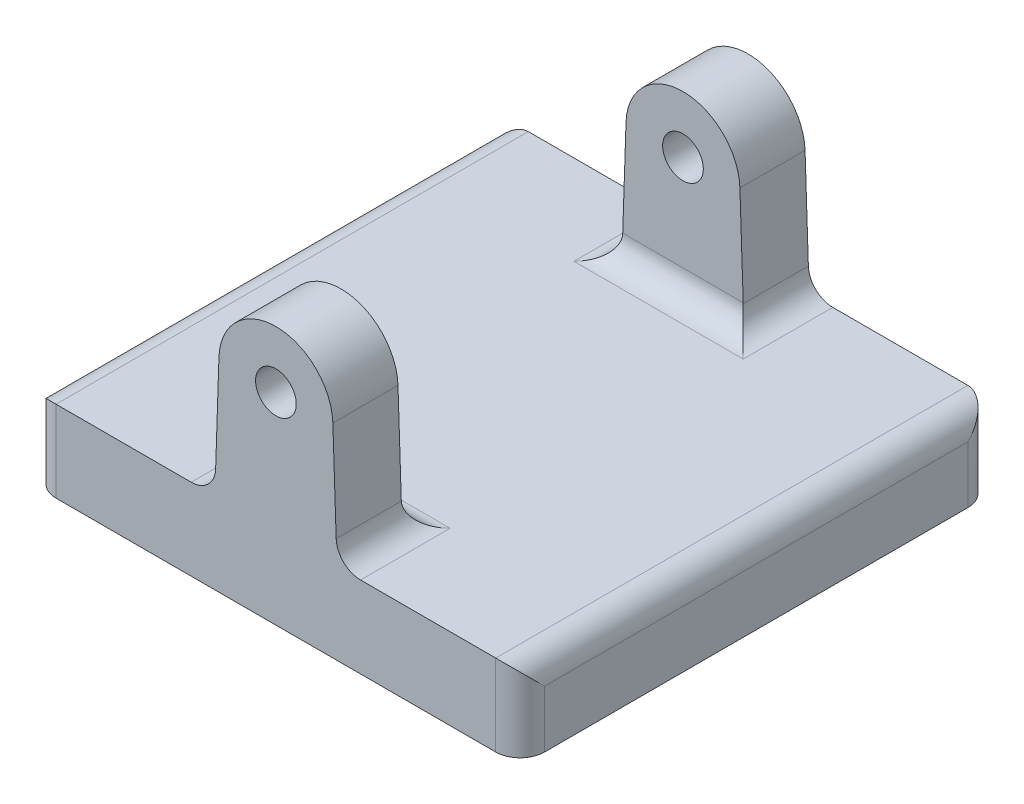
from build123d import *

# Parameters (mm, degrees)
SKETCH2_W           = 60
SKETCH2_H           = 58
BOSS_EXTRUDE1_DEPTH = 10
SKETCH3_R           = 2.5
BOSS_EXTRUDE2_DEPTH = 8
FILLET1_R           = 3


with BuildPart() as part:
    # Sketch2 → Boss-Extrude1 (new body)
    with BuildSketch(Plane(origin=(0, 0, 0), x_dir=(1, 0, 0), z_dir=(0, 1, 0))):
        Rectangle(SKETCH2_W, SKETCH2_H)
    extrude(amount=BOSS_EXTRUDE1_DEPTH)

    # Sketch3 → Boss-Extrude2 (add)
    with BuildSketch(Plane.XY.offset(29)):
        with BuildLine():
            Line((-7.5, 10), (-6.996052809, 25))
            ThreePointArc((-6.996052809, 25), (0, 31.764957256), (6.996052809, 25))
            Line((6.996052809, 25), (7.5, 10))
            Line((7.5, 10), (-7.5, 10))
        make_face()
        with Locations((0, 24.764957256)):
            Circle(SKETCH3_R, mode=Mode.SUBTRACT)
    boss_extrude2 = extrude(amount=-BOSS_EXTRUDE2_DEPTH)

    # Mirror1: Boss-Extrude2 across plane
    add(boss_extrude2.mirror(Plane.XY))

    # Fillet1
    fillet1_edges = [part.edges().sort_by_distance(p)[0] for p in [
        (-30, 10, 0),
        (0, 10, 21),
        (7.5, 10, 25),
        (-7.5, 10, 25),
        (0, 10, -21),
        (-7.5, 10, -25),
        (7.5, 10, -25),
        (30, 10, 0),
        (30, 5, 29),
        (-30, 5, 29),
        (-30, 5, -29),
        (30, 5, -29),
    ]]
    fillet(fillet1_edges, radius=FILLET1_R)


solid = part.part
